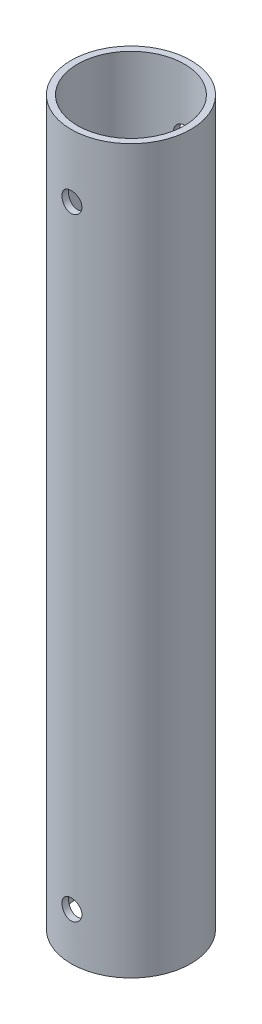
from build123d import *

# Parameters (mm, degrees)
CROQUIS2_R                 = 9.525
CROQUIS2_R_2               = 8.5
SALIENTE_EXTRUIR1_DEPTH    = 115
CROQUIS3_R                 = 1.5875
CORTAR_EXTRUIR1_DEPTH      = 10.525
CORTAR_EXTRUIR1_DEPTH_BACK = 10.525


with BuildPart() as part:
    # Croquis2 → Saliente-Extruir1 (new body)
    with BuildSketch(Plane(origin=(0, 0, 0), x_dir=(1, 0, 0), z_dir=(0, 1, 0))):
        Circle(CROQUIS2_R)
        Circle(CROQUIS2_R_2, mode=Mode.SUBTRACT)
    extrude(amount=SALIENTE_EXTRUIR1_DEPTH)

    # Croquis3 → Cortar-Extruir1 (cut, two sides)
    with BuildSketch(Plane.XY) as cortar_extruir1_sk:
        with Locations((0, 105)):
            Circle(CROQUIS3_R)
        with Locations((0, 7.5)):
            Circle(CROQUIS3_R)
    extrude(amount=CORTAR_EXTRUIR1_DEPTH, mode=Mode.SUBTRACT)
    extrude(cortar_extruir1_sk.sketch, amount=-CORTAR_EXTRUIR1_DEPTH_BACK, mode=Mode.SUBTRACT)


solid = part.part
